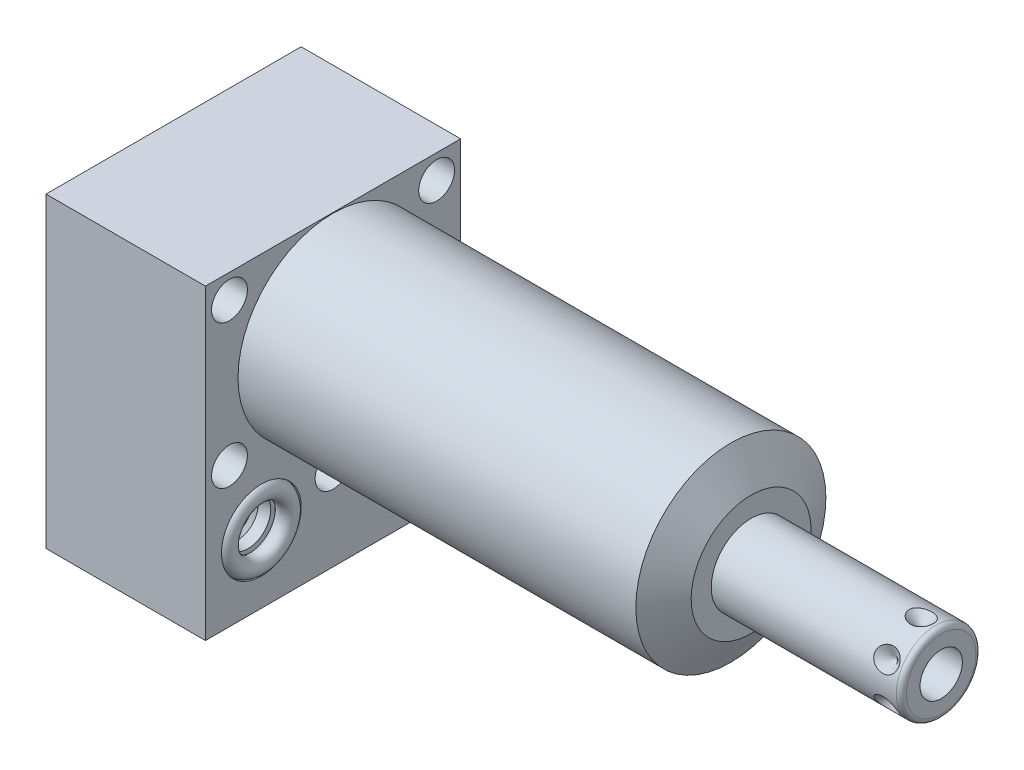
from build123d import *

# Parameters (mm, degrees)
SKETCH1_W           = 50.8
SKETCH1_H           = 61.1124
EXTRUDE1_DEPTH      = 83.2358
EXTRUDE1_DEPTH_BACK = 31.75
CUT_EXTRUDE1_REACH  = 85.236
SKETCH2_W           = 50.8
SKETCH2_H           = 61.1124
SKETCH2_R           = 18.923
SKETCH18_R          = 7.9375
CUT_EXTRUDE2_DEPTH  = 2.667
SKETCH19_R          = 7.9375
CUT_EXTRUDE3_DEPTH  = 2.667
SKETCH20_R          = 9.525
CUT_EXTRUDE4_DEPTH  = 0.254
SKETCH14_R          = 1.7653
SKETCH15_R          = 1.7653
CIRPATTERN1_COUNT   = 6
SKETCH21_W          = 3.5687
SKETCH21_H          = 31.75
HOLE1_AT_2_COUNT    = 2
HOLE1_AT_2_PITCH    = 44.445239059
HOLE1_AT_3_COUNT    = 2
HOLE1_AT_3_PITCH    = 28.5496
HOLE1_AT_4_COUNT    = 2
HOLE1_AT_4_PITCH    = 41.2496
HOLE1_AT_5_COUNT    = 2
HOLE1_AT_5_PITCH    = 50.165816652
LPATTERN1_COUNT     = 2
LPATTERN1_PITCH     = 28.5496


with BuildPart() as part:
    # Sketch1 → Extrude1 (new body, two sides)
    with BuildSketch(Plane(origin=(0, 0, 0), x_dir=(0, 0, -1), z_dir=(1, 0, 0))) as extrude1_sk:
        with Locations((0, -11.5062)):
            Rectangle(SKETCH1_W, SKETCH1_H)
    extrude(amount=EXTRUDE1_DEPTH)
    extrude(extrude1_sk.sketch, amount=-EXTRUDE1_DEPTH_BACK)

    # Sketch2 → Cut-Extrude1 (cut, up to next)
    with BuildSketch(Plane(origin=(0, 0, 0), x_dir=(0, 0, -1), z_dir=(1, 0, 0)), mode=Mode.PRIVATE) as cut_extrude1_sk1:
        with Locations((0, -11.5062)):
            Rectangle(SKETCH2_W, SKETCH2_H)
        Circle(SKETCH2_R, mode=Mode.SUBTRACT)
    cut_extrude1_tool1 = extrude(cut_extrude1_sk1.sketch, amount=CUT_EXTRUDE1_REACH, mode=Mode.PRIVATE) & part.part
    add(cut_extrude1_tool1.solids().sort_by_distance((0, 18.970531, 0))[0], mode=Mode.SUBTRACT)

    # Sketch3 → Cut-Revolve1 (revolve, cut)
    with BuildSketch(Plane.XY, mode=Mode.PRIVATE) as cut_revolve1_sk:
        Polygon((79.20300837, 18.923), (83.2358, 11.938), (83.2358, 18.923), align=None)
    revolve(cut_revolve1_sk.sketch.rotate(Axis((56.700168788, 0, 0), (1, 0, 0)), 90), axis=Axis((56.700168788, 0, 0), (1, 0, 0)), mode=Mode.SUBTRACT)  # turned: the seam where the file's is

    # S2D0002 → Cut-Revolve2 (revolve, cut)
    with BuildSketch(Plane(origin=(-29.083, -28.575, 14.2748), x_dir=(0, 1, 0), z_dir=(0, 0, 1)), mode=Mode.PRIVATE) as cut_revolve2_sk:
        Polygon((0, 0), (4.5466, 0), (4.106586662, -2.0701), (3.4544, -2.722286662), (3.4544, -13.97), (0, -13.97), align=None)
    revolve(cut_revolve2_sk.sketch.rotate(Axis((-14.4145, -28.575, 14.2748), (-1, 0, 0)), 90), axis=Axis((-14.4145, -28.575, 14.2748), (-1, 0, 0)), mode=Mode.SUBTRACT)  # turned: the seam where the file's is

    # Sketch5 → Cut-Revolve3 (revolve, cut)
    with BuildSketch(Plane(origin=(-29.083, -28.575, -14.2748), x_dir=(0, 1, 0), z_dir=(0, 0, 1)), mode=Mode.PRIVATE) as cut_revolve3_sk:
        Polygon((0, 0), (4.5466, 0), (4.106586662, -2.0701), (3.4544, -2.722286662), (3.4544, -13.97), (0, -13.97), align=None)
    revolve(cut_revolve3_sk.sketch.rotate(Axis((-14.4145, -28.575, -14.2748), (-1, 0, 0)), 90), axis=Axis((-14.4145, -28.575, -14.2748), (-1, 0, 0)), mode=Mode.SUBTRACT)  # turned: the seam where the file's is

    # Sketch6 → Cut-Revolve4 (revolve, cut)
    with BuildSketch(Plane(origin=(-2.667, -28.575, 14.2748), x_dir=(0, -1, 0), z_dir=(0, 0, 1)), mode=Mode.PRIVATE) as cut_revolve4_sk:
        Polygon((0, 0), (4.5466, 0), (4.106586662, -2.0701), (3.4544, -2.722286662), (3.4544, -12.192), (0, -12.192), align=None)
    revolve(cut_revolve4_sk.sketch.rotate(Axis((-15.4686, -28.575, 14.2748), (1, 0, 0)), 90), axis=Axis((-15.4686, -28.575, 14.2748), (1, 0, 0)), mode=Mode.SUBTRACT)  # turned: the seam where the file's is

    # Sketch7 → Cut-Revolve5 (revolve, cut)
    with BuildSketch(Plane(origin=(-2.667, -28.575, -14.2748), x_dir=(0, -1, 0), z_dir=(0, 0, 1)), mode=Mode.PRIVATE) as cut_revolve5_sk:
        Polygon((0, 0), (4.5466, 0), (4.106586662, -2.0701), (3.4544, -2.722286662), (3.4544, -12.192), (0, -12.192), align=None)
    revolve(cut_revolve5_sk.sketch.rotate(Axis((-15.4686, -28.575, -14.2748), (1, 0, 0)), 90), axis=Axis((-15.4686, -28.575, -14.2748), (1, 0, 0)), mode=Mode.SUBTRACT)  # turned: the seam where the file's is

    # Sketch18 → Cut-Extrude2 (cut)
    with BuildSketch(Plane.ZY.offset(31.75)):
        with Locations((-14.2748, -28.575)):
            Circle(SKETCH18_R)
        with Locations((14.2748, -28.575)):
            Circle(SKETCH18_R)
    extrude(amount=-CUT_EXTRUDE2_DEPTH, mode=Mode.SUBTRACT)

    # Sketch19 → Cut-Extrude3 (cut)
    with BuildSketch(Plane(origin=(0, 0, 0), x_dir=(0, 0, -1), z_dir=(1, 0, 0))):
        with Locations((-14.2748, -28.575)):
            Circle(SKETCH19_R)
        with Locations((14.2748, -28.575)):
            Circle(SKETCH19_R)
    extrude(amount=-CUT_EXTRUDE3_DEPTH, mode=Mode.SUBTRACT)

    # Sketch8 → Cut-Revolve6 (revolve, cut)
    with BuildSketch(Plane(origin=(-15.875, -43.688, 14.2748), x_dir=(-1, 0, 0), z_dir=(0, 0, 1)), mode=Mode.PRIVATE) as cut_revolve6_sk:
        Polygon((0, -1.8796), (6.1849, -1.8796), (5.642306865, -4.4323), (4.9784, -5.096206865), (4.9784, -20.9296), (0, -20.9296), align=None)
    revolve(cut_revolve6_sk.sketch.rotate(Axis((-15.875, -17.018, 14.2748), (0, -1, 0)), 270), axis=Axis((-15.875, -17.018, 14.2748), (0, -1, 0)), mode=Mode.SUBTRACT)  # turned: the seam where the file's is

    # Sketch9 → Cut-Revolve7 (revolve, cut)
    with BuildSketch(Plane(origin=(-15.875, -43.688, -14.2748), x_dir=(-1, 0, 0), z_dir=(0, 0, 1)), mode=Mode.PRIVATE) as cut_revolve7_sk:
        Polygon((0, -1.8796), (6.1849, -1.8796), (5.642306865, -4.4323), (4.9784, -5.096206865), (4.9784, -20.9296), (0, -20.9296), align=None)
    revolve(cut_revolve7_sk.sketch.rotate(Axis((-15.875, -17.018, -14.2748), (0, -1, 0)), 270), axis=Axis((-15.875, -17.018, -14.2748), (0, -1, 0)), mode=Mode.SUBTRACT)  # turned: the seam where the file's is

    # Sketch20 → Cut-Extrude4 (cut)
    with BuildSketch(Plane.XZ.offset(42.0624)):
        with Locations(Location((-15.875, 14.2748, 0), (0, 0, 270))):  # turned: the seam where the file's is
            Circle(SKETCH20_R)
        with Locations(Location((-15.875, -14.2748, 0), (0, 0, 270))):  # turned: the seam where the file's is
            Circle(SKETCH20_R)
    extrude(amount=-CUT_EXTRUDE4_DEPTH, mode=Mode.SUBTRACT)

    # Sketch10 → Revolve1 (revolve)
    with BuildSketch(Plane.XY, mode=Mode.PRIVATE) as revolve1_sk:
        with BuildLine():
            Line((83.2358, 0), (83.2358, 7.9375))
            Line((83.2358, 7.9375), (120.0658, 7.9375))
            ThreePointArc((120.0658, 7.9375), (120.78422049, 7.63992049), (121.0818, 6.9215))
            Line((121.0818, 6.9215), (121.0818, 0))
            Line((121.0818, 0), (83.2358, 0))
        make_face()
    revolve(revolve1_sk.sketch.rotate(Axis((59.59348, 0, 0), (1, 0, 0)), 90), axis=Axis((59.59348, 0, 0), (1, 0, 0)))  # turned: the seam where the file's is

    # S2D0001 → Cut-Revolve8 (revolve, cut)
    with BuildSketch(Plane(origin=(87.757, -4.2164, 0), x_dir=(0, -1, 0), z_dir=(0, 0, 1)), mode=Mode.PRIVATE) as cut_revolve8_sk:
        Polygon((0, 33.3248), (0, 18.0848), (-4.2164, 15.551331286), (-4.2164, 33.3248), align=None)
    revolve(cut_revolve8_sk.sketch.rotate(Axis((62.891960697, 0, 0), (1, 0, 0)), 270), axis=Axis((62.891960697, 0, 0), (1, 0, 0)), mode=Mode.SUBTRACT)  # turned: the seam where the file's is

    # Sketch16 → Cut-Revolve9 (revolve, cut)
    with BuildSketch(Plane(origin=(83.7946, -7.9375, 0), x_dir=(-1, 0, 0), z_dir=(0, 0, 1)), mode=Mode.PRIVATE) as cut_revolve9_sk:
        Polygon((-33.3248, 0), (-30.9118, 0), (-33.3248, -2.413), align=None)
    cut_revolve9 = revolve(cut_revolve9_sk.sketch.rotate(Axis((117.1194, -4.132061843, 0), (0, -1, 0)), 90), axis=Axis((117.1194, -4.132061843, 0), (0, -1, 0)), mode=Mode.SUBTRACT)  # turned: the seam where the file's is

    # CirPattern1: Cut-Revolve9 ×6 about axis
    cirpattern1_axis = Axis((83.2368, 0, 0), (-1, 0, 0))
    for i in range(1, CIRPATTERN1_COUNT):
        add(cut_revolve9.rotate(cirpattern1_axis, i * 360 / CIRPATTERN1_COUNT), mode=Mode.SUBTRACT)

    # Sketch21 → Hole1 (revolve, cut)
    with BuildSketch(Plane(origin=(0, 14.2748, 20.6248), x_dir=(0, 0, -1), z_dir=(0, 1, 0))):
        with Locations((1.78435, 15.875)):
            Rectangle(SKETCH21_W, SKETCH21_H)
    hole1 = revolve(axis=Axis((-110, 14.2748, 20.6248), (1, 0, 0)), mode=Mode.SUBTRACT)

    # Hole1 at 2: Hole1 ×2
    with Locations(*[Vector(0, -0.885809163, -0.464049703) * (i * HOLE1_AT_2_PITCH) for i in range(1, HOLE1_AT_2_COUNT)]):
        add(hole1, mode=Mode.SUBTRACT)

    # Hole1 at 3: Hole1 ×2
    with Locations(*[(0, -i * HOLE1_AT_3_PITCH, 0) for i in range(1, HOLE1_AT_3_COUNT)]):
        add(hole1, mode=Mode.SUBTRACT)

    # Hole1 at 4: Hole1 ×2
    with Locations(*[(0, 0, -i * HOLE1_AT_4_PITCH) for i in range(1, HOLE1_AT_4_COUNT)]):
        add(hole1, mode=Mode.SUBTRACT)

    # Hole1 at 5: Hole1 ×2
    with Locations(*[Vector(0, -0.569104659, -0.822265095) * (i * HOLE1_AT_5_PITCH) for i in range(1, HOLE1_AT_5_COUNT)]):
        add(hole1, mode=Mode.SUBTRACT)


with BuildPart() as body_2:
    # Sketch14 → Revolve2 (revolve)
    with BuildSketch(Plane(origin=(0, -28.575, -14.2748), x_dir=(0, 0, -1), z_dir=(0, -1, 0)), mode=Mode.PRIVATE) as revolve2_sk:
        with Locations((6.1722, -0.9017)):
            Circle(SKETCH14_R)
    revolve2 = revolve(revolve2_sk.sketch.rotate(Axis((-2.84353, -28.575, -14.2748), (1, 0, 0)), 180), axis=Axis((-2.84353, -28.575, -14.2748), (1, 0, 0)))  # turned: the seam where the file's is


with BuildPart() as body_3:
    # Sketch15 → Revolve3 (revolve)
    with BuildSketch(Plane(origin=(0, -28.575, -14.2748), x_dir=(0, 0, -1), z_dir=(0, -1, 0)), mode=Mode.PRIVATE) as revolve3_sk:
        with Locations((6.1722, -30.8483)):
            Circle(SKETCH15_R)
    revolve3 = revolve(revolve3_sk.sketch.rotate(Axis((-32.79013, -28.575, -14.2748), (1, 0, 0)), 180), axis=Axis((-32.79013, -28.575, -14.2748), (1, 0, 0)))  # turned: the seam where the file's is


with BuildPart() as lpattern1_1:
    # LPattern1: Revolve2, Revolve3 ×2
    with Locations(*[(0, 0, i * LPATTERN1_PITCH) for i in range(1, LPATTERN1_COUNT)]):
        add(revolve2)
        add(revolve3)


solid = Compound([part.part, body_2.part, body_3.part, lpattern1_1.part])
